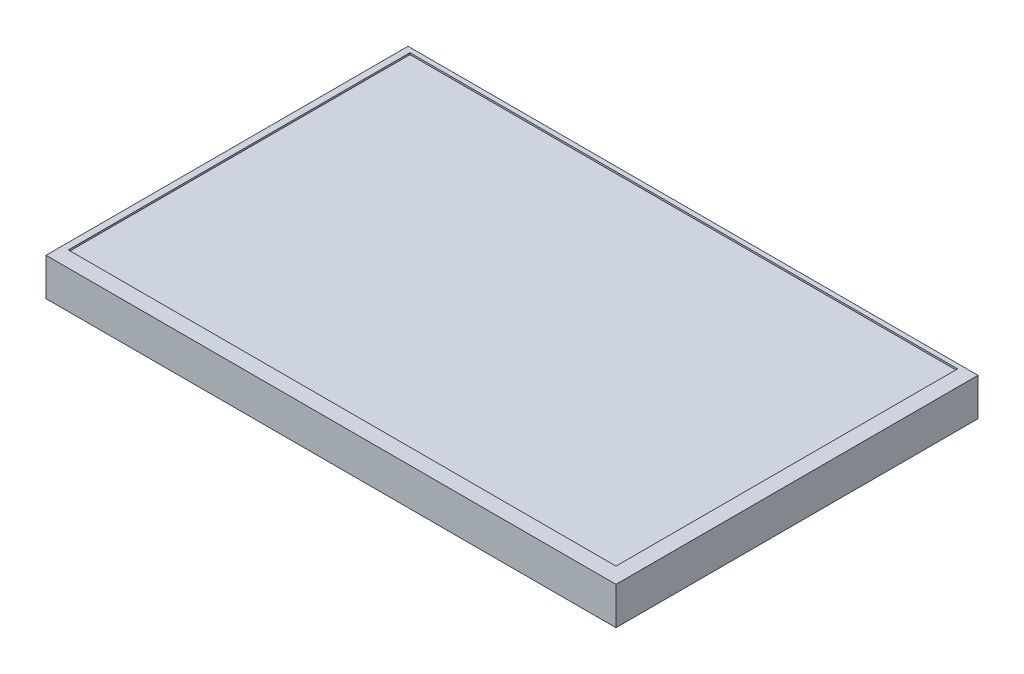
from build123d import *

# Parameters (mm, degrees)
SKETCH1_W           = 166
SKETCH1_H           = 105.44
BOSS_EXTRUDE1_DEPTH = 10.95
SKETCH2_W           = 159.5
SKETCH2_H           = 99.49
CUT_EXTRUDE1_DEPTH  = 0.5


with BuildPart() as part:
    # Sketch1 → Boss-Extrude1 (new body)
    with BuildSketch(Plane(origin=(0, 0, 0), x_dir=(1, 0, 0), z_dir=(0, 1, 0))):
        Rectangle(SKETCH1_W, SKETCH1_H)
    extrude(amount=BOSS_EXTRUDE1_DEPTH)

    # Sketch2 → Cut-Extrude1 (cut)
    with BuildSketch(Plane(origin=(0, 10.95, 0), x_dir=(1, 0, 0), z_dir=(0, 1, 0))):
        with Locations((-1.35, 1.625)):
            Rectangle(SKETCH2_W, SKETCH2_H)
    extrude(amount=-CUT_EXTRUDE1_DEPTH, mode=Mode.SUBTRACT)


solid = part.part
